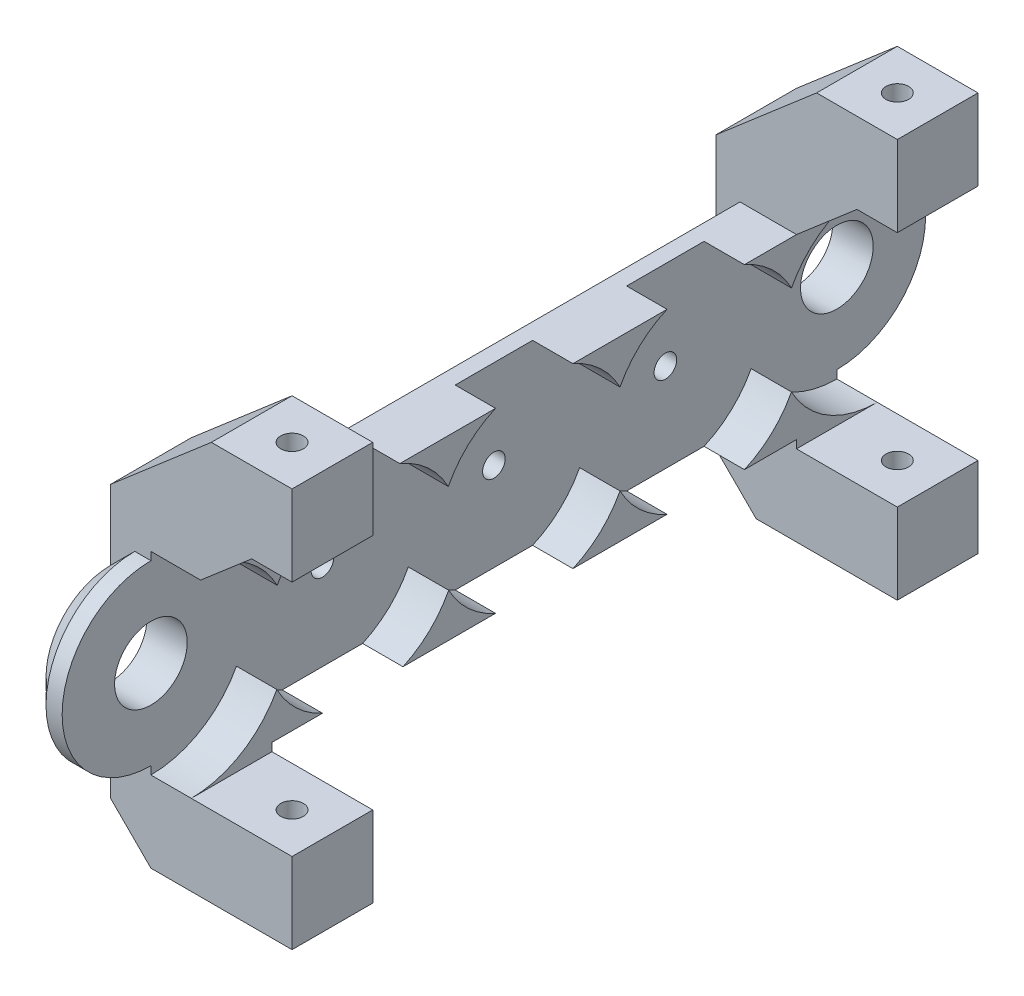
from build123d import *

# Parameters (mm, degrees)
SKETCH1_R                  = 4.5
BOSS_EXTRUDE1_DEPTH        = 10
SKETCH3_R                  = 1.4
CUT_EXTRUDE1_DEPTH         = 11
BOSS_EXTRUDE2_DEPTH        = 10
LPATTERN1_COUNT            = 2
LPATTERN1_PITCH            = 75
SKETCH8_W                  = 10
SKETCH8_H                  = 10
BOSS_EXTRUDE3_DEPTH        = 1
BOSS_EXTRUDE5_START        = -10
SKETCH10_W                 = 10
SKETCH10_H                 = 10
BOSS_EXTRUDE5_DEPTH        = 22.48966
CHAMFER3_SIZE              = 5
LPATTERN3_COUNT            = 2
LPATTERN3_PITCH            = 75
CHAMFER3_OF_LPATTERN3_SIZE = 5
SKETCH6_R                  = 4.5
SKETCH6_R_2                = 1.4
SKETCH6_R_3                = 12
CUT_EXTRUDE3_DEPTH         = 10
CUT_EXTRUDE3_DEPTH_BACK    = 5
SKETCH15_R                 = 1.4
CUT_EXTRUDE4_DEPTH         = 70
CHAMFER4_SIZE              = 3


with BuildPart() as part:
    # Sketch1 → Boss-Extrude1 (new body)
    with BuildSketch(Plane(origin=(0, 0, 0), x_dir=(0, 0, -1), z_dir=(1, 0, 0))):
        with BuildLine():
            Line((0, 11), (85, 11))
            ThreePointArc((85, 11), (96, 0), (85, -11))
            Line((85, -11), (0, -11))
            ThreePointArc((0, -11), (-11, 0), (0, 11))
        make_face()
        Circle(SKETCH1_R, mode=Mode.SUBTRACT)
        with Locations((85, 0)):
            Circle(SKETCH1_R, mode=Mode.SUBTRACT)
    extrude(amount=BOSS_EXTRUDE1_DEPTH)

    # Sketch3 → Cut-Extrude1 (cut, through all)
    with BuildSketch(Plane.ZY):
        with Locations((-42.5, 0)):
            Circle(SKETCH3_R)
        with Locations((-63.75, 0)):
            Circle(SKETCH3_R)
        with Locations((-21.25, 0)):
            Circle(SKETCH3_R)
        with Locations((-148.75, 0)):
            Circle(SKETCH3_R)
        with Locations((-127.5, 0)):
            Circle(SKETCH3_R)
        with Locations((-106.25, 0)):
            Circle(SKETCH3_R)
    extrude(amount=-CUT_EXTRUDE1_DEPTH, mode=Mode.SUBTRACT)

    # Sketch8 → Boss-Extrude3 (add)
    with BuildSketch(Plane(origin=(0, -11, 0), x_dir=(-1, 0, 0), z_dir=(0, -1, 0))):
        with Locations((-5, 5)):
            Rectangle(SKETCH8_W, SKETCH8_H)
    boss_extrude3 = extrude(amount=BOSS_EXTRUDE3_DEPTH)

    # Sketch10 → Boss-Extrude5 (add)
    with BuildSketch(Plane(origin=(10, 0, 0), x_dir=(0, 0, -1), z_dir=(1, 0, 0)).offset(BOSS_EXTRUDE5_START)):
        with Locations((5, -17)):
            Rectangle(SKETCH10_W, SKETCH10_H)
    boss_extrude5 = extrude(amount=BOSS_EXTRUDE5_DEPTH)

    # Chamfer3
    chamfer3_edges = [part.edges().sort_by_distance(p)[0] for p in [
        (0, -22, -5),
    ]]
    chamfer(chamfer3_edges, length=CHAMFER3_SIZE)

    # LPattern3: Boss-Extrude3, Boss-Extrude5 ×2
    with Locations(*[(0, 0, -i * LPATTERN3_PITCH) for i in range(1, LPATTERN3_COUNT)]):
        add(boss_extrude3)
        add(boss_extrude5)

    # Chamfer3 of LPattern3
    chamfer3_of_lpattern3_edges = [part.edges().sort_by_distance(p)[0] for p in [
        (0, -22, -80),
    ]]
    chamfer(chamfer3_of_lpattern3_edges, length=CHAMFER3_OF_LPATTERN3_SIZE)


with BuildPart() as body_2:
    # Sketch7 → Boss-Extrude2 (new body)
    with BuildSketch(Plane.XY):
        Polygon((0, 11), (0, 16.697133846), (12.489660366, 27.445401219), (22.489660366, 27.445401219), (22.489660366, 17.445401219), (17.489660366, 17.445401219), (10, 11), align=None)
    boss_extrude2 = extrude(amount=-BOSS_EXTRUDE2_DEPTH)


with BuildPart() as lpattern1_1:
    # LPattern1: Boss-Extrude2 ×2
    with Locations(*[(0, 0, -i * LPATTERN1_PITCH) for i in range(1, LPATTERN1_COUNT)]):
        add(boss_extrude2)


with BuildPart() as body_2_1:
    add(body_2.part)

    # Combine1: union part, LPattern1_1
    add(part.part)
    add(lpattern1_1.part)

    # Sketch6 → Cut-Extrude3 (cut, two sides)
    with BuildSketch(Plane(origin=(10, 0, 0), x_dir=(0, 0, -1), z_dir=(1, 0, 0))) as cut_extrude3_sk:
        with BuildLine():
            ThreePointArc((10.602696958, -5.619859181), (9.250095943, -0.036989697), (10.647303042, 5.534883732))
            ThreePointArc((10.647303042, 5.534883732), (8.190816519, 8.76986458), (4.795831523, 11))
            Line((4.795831523, 11), (0, 11))
            ThreePointArc((0, 11), (-11, 0), (0, -11))
            Line((0, -11), (4.795831523, -11))
            ThreePointArc((4.795831523, -11), (8.155681986, -8.802548003), (10.602696958, -5.619859181))
        make_face()
        Circle(SKETCH6_R, mode=Mode.SUBTRACT)
        with BuildLine():
            ThreePointArc((10.647303042, 5.534883732), (11.656921474, 2.848891319), (12, 0))
            ThreePointArc((12, 0), (11.645436091, -2.895482387), (10.602696958, -5.619859181))
            ThreePointArc((10.602696958, -5.619859181), (12.983312559, -8.783359135), (16.263795125, -11))
            Line((16.263795125, -11), (26.236204875, -11))
            ThreePointArc((26.236204875, -11), (29.516687441, -8.783359135), (31.897303042, -5.619859181))
            ThreePointArc((31.897303042, -5.619859181), (30.500095943, -0.047985752), (31.852696958, 5.534883732))
            ThreePointArc((31.852696958, 5.534883732), (29.325707811, 8.791000179), (25.846011237, 11))
            Line((25.846011237, 11), (16.653988763, 11))
            ThreePointArc((16.653988763, 11), (13.174292189, 8.791000179), (10.647303042, 5.534883732))
        make_face()
        with Locations((21.25, 0)):
            Circle(SKETCH6_R_2, mode=Mode.SUBTRACT)
        Circle(SKETCH6_R_3)
        with Locations((21.25, -0.084975449)):
            Circle(SKETCH6_R_3)
        with BuildLine():
            ThreePointArc((37.704168477, 11), (34.309183481, 8.76986458), (31.852696958, 5.534883732))
            ThreePointArc((31.852696958, 5.534883732), (32.895436091, 2.810506938), (33.25, -0.084975449))
            ThreePointArc((33.25, -0.084975449), (32.906921474, -2.933866768), (31.897303042, -5.619859181))
            ThreePointArc((31.897303042, -5.619859181), (34.344318014, -8.802548003), (37.704168477, -11))
            Line((37.704168477, -11), (47.295831523, -11))
            ThreePointArc((47.295831523, -11), (50.673198678, -8.786286096), (53.125, -5.577577879))
            ThreePointArc((53.125, -5.577577879), (51.75, 0), (53.125, 5.577577879))
            ThreePointArc((53.125, 5.577577879), (50.673198678, 8.786286096), (47.295831523, 11))
            Line((47.295831523, 11), (37.704168477, 11))
        make_face()
        with Locations((42.5, 0)):
            Circle(SKETCH6_R_2, mode=Mode.SUBTRACT)
        with Locations((42.5, 0)):
            Circle(SKETCH6_R_3)
        with BuildLine():
            ThreePointArc((58.954168477, 11), (55.576801322, 8.786286096), (53.125, 5.577577879))
            ThreePointArc((53.125, 5.577577879), (54.151180198, 2.872281323), (54.5, 0))
            ThreePointArc((54.5, 0), (54.151180198, -2.872281323), (53.125, -5.577577879))
            ThreePointArc((53.125, -5.577577879), (55.576801322, -8.786286096), (58.954168477, -11))
            Line((58.954168477, -11), (68.545831523, -11))
            ThreePointArc((68.545831523, -11), (71.923198678, -8.786286096), (74.375, -5.577577879))
            ThreePointArc((74.375, -5.577577879), (73, 0), (74.375, 5.577577879))
            ThreePointArc((74.375, 5.577577879), (71.923198678, 8.786286096), (68.545831523, 11))
            Line((68.545831523, 11), (58.954168477, 11))
        make_face()
        with Locations((63.75, 0)):
            Circle(SKETCH6_R_2, mode=Mode.SUBTRACT)
        with Locations((63.75, 0)):
            Circle(SKETCH6_R_3)
        with Locations((85, 0)):
            Circle(SKETCH6_R_3)
        with BuildLine():
            ThreePointArc((80.204168477, 11), (76.826801322, 8.786286096), (74.375, 5.577577879))
            ThreePointArc((74.375, 5.577577879), (75.401180198, 2.872281323), (75.75, 0))
            ThreePointArc((75.75, 0), (75.401180198, -2.872281323), (74.375, -5.577577879))
            ThreePointArc((74.375, -5.577577879), (76.826801322, -8.786286096), (80.204168477, -11))
            Line((80.204168477, -11), (85, -11))
            ThreePointArc((85, -11), (96, 0), (85, 11))
            Line((85, 11), (80.204168477, 11))
        make_face()
        with Locations((85, 0)):
            Circle(SKETCH6_R, mode=Mode.SUBTRACT)
        with BuildLine():
            Line((0, 11), (4.795831523, 11))
            ThreePointArc((4.795831523, 11), (-12, 0), (4.795831523, -11))
            Line((4.795831523, -11), (0, -11))
            ThreePointArc((0, -11), (-11, 0), (0, 11))
        make_face()
        with BuildLine():
            ThreePointArc((97, 0), (91.574573055, 10.03867467), (80.204168477, 11))
            Line((80.204168477, 11), (85, 11))
            ThreePointArc((85, 11), (96, 0), (85, -11))
            Line((85, -11), (80.204168477, -11))
            ThreePointArc((80.204168477, -11), (91.574573055, -10.03867467), (97, 0))
        make_face()
    extrude(amount=CUT_EXTRUDE3_DEPTH, mode=Mode.SUBTRACT)
    extrude(cut_extrude3_sk.sketch, amount=-CUT_EXTRUDE3_DEPTH_BACK, mode=Mode.SUBTRACT)

    # Sketch15 → Cut-Extrude4 (cut)
    with BuildSketch(Plane(origin=(0, 27.445401219, 0), x_dir=(1, 0, 0), z_dir=(0, 1, 0))):
        with Locations((17.489660366, 80)):
            Circle(SKETCH15_R)
        with Locations((17.489660366, 5)):
            Circle(SKETCH15_R)
    extrude(amount=-CUT_EXTRUDE4_DEPTH, mode=Mode.SUBTRACT)

    # Chamfer4
    chamfer4_edges = [body_2_1.edges().sort_by_distance(p)[0] for p in [
        (0, -11, -42.5),
        (0, 11, -42.5),
        (0, 0, -96),
        (0, 0, 11),
    ]]
    chamfer(chamfer4_edges, length=CHAMFER4_SIZE)


solid = body_2_1.part
